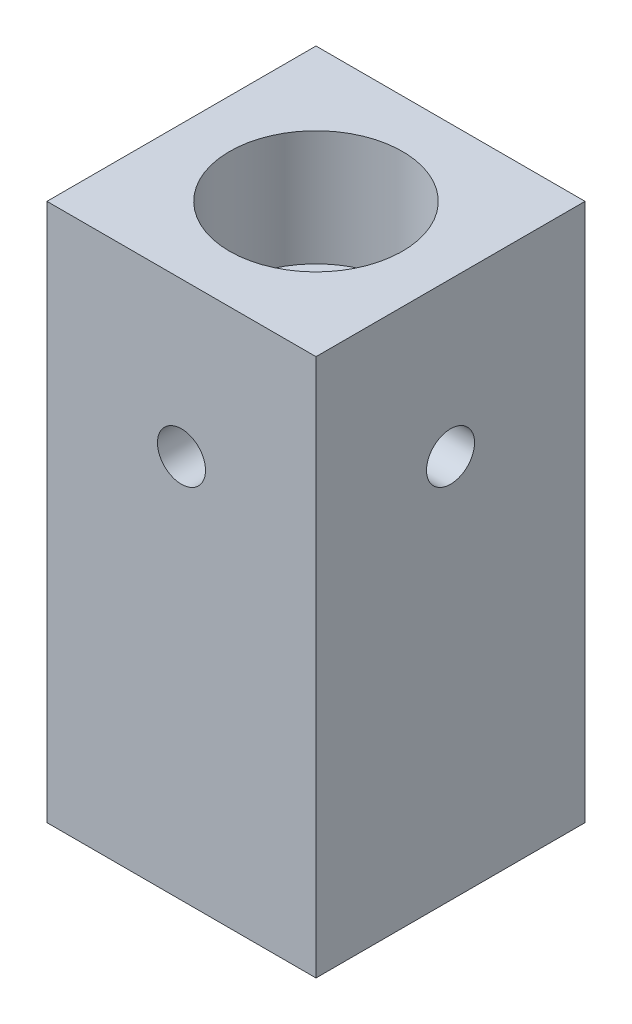
from build123d import *

# Parameters (mm, degrees)
SKETCH1_W                  = 22.225
SKETCH1_H                  = 22.225
BOSS_EXTRUDE1_DEPTH        = 44.45
M10X1_5_TAPPED_HOLE1_D     = 8.5
M10X1_5_TAPPED_HOLE1_DEPTH = 24.638
M10X1_5_TAPPED_HOLE1_TIP   = 2.553657631
SKETCH9_R                  = 4.25
CUT_EXTRUDE1_DEPTH         = 19.05
SKETCH10_R                 = 7.14375
CUT_EXTRUDE2_DEPTH         = 9.525
SKETCH11_R                 = 1.984375
CUT_EXTRUDE3_DEPTH         = 23.225
SKETCH12_R                 = 1.984375
CUT_EXTRUDE4_DEPTH         = 23.225


with BuildPart() as part:
    # Sketch1 → Boss-Extrude1 (new body)
    with BuildSketch(Plane(origin=(0, 0, 0), x_dir=(1, 0, 0), z_dir=(0, 1, 0))):
        Rectangle(SKETCH1_W, SKETCH1_H)
    extrude(amount=BOSS_EXTRUDE1_DEPTH)

    # M10x1.5 Tapped Hole1
    with Locations(Plane(origin=(0, 0, 0), x_dir=(-1, 0, 0), z_dir=(0, -1, 0))):
        with Locations((0, 0)):
            Hole(M10X1_5_TAPPED_HOLE1_D / 2, depth=M10X1_5_TAPPED_HOLE1_DEPTH)
            with Locations((0, 0, -(M10X1_5_TAPPED_HOLE1_DEPTH + M10X1_5_TAPPED_HOLE1_TIP / 2))):  # 118° drill point
                Cone(0, M10X1_5_TAPPED_HOLE1_D / 2, M10X1_5_TAPPED_HOLE1_TIP, mode=Mode.SUBTRACT)

    # Sketch9 → Cut-Extrude1 (cut)
    with BuildSketch(Plane(origin=(0, 44.45, 0), x_dir=(1, 0, 0), z_dir=(0, 1, 0))):
        Circle(SKETCH9_R)
    extrude(amount=-CUT_EXTRUDE1_DEPTH, mode=Mode.SUBTRACT)

    # Sketch10 → Cut-Extrude2 (cut)
    with BuildSketch(Plane(origin=(0, 44.45, 0), x_dir=(1, 0, 0), z_dir=(0, 1, 0))):
        Circle(SKETCH10_R)
    extrude(amount=-CUT_EXTRUDE2_DEPTH, mode=Mode.SUBTRACT)

    # Sketch11 → Cut-Extrude3 (cut, through all)
    with BuildSketch(Plane(origin=(11.1125, 0, 0), x_dir=(0, 0, -1), z_dir=(1, 0, 0))):
        with Locations((0, 31.75)):
            Circle(SKETCH11_R)
    extrude(amount=-CUT_EXTRUDE3_DEPTH, mode=Mode.SUBTRACT)

    # Sketch12 → Cut-Extrude4 (cut, through all)
    with BuildSketch(Plane.XY.offset(11.1125)):
        with Locations((0, 31.75)):
            Circle(SKETCH12_R)
    extrude(amount=-CUT_EXTRUDE4_DEPTH, mode=Mode.SUBTRACT)


solid = part.part
